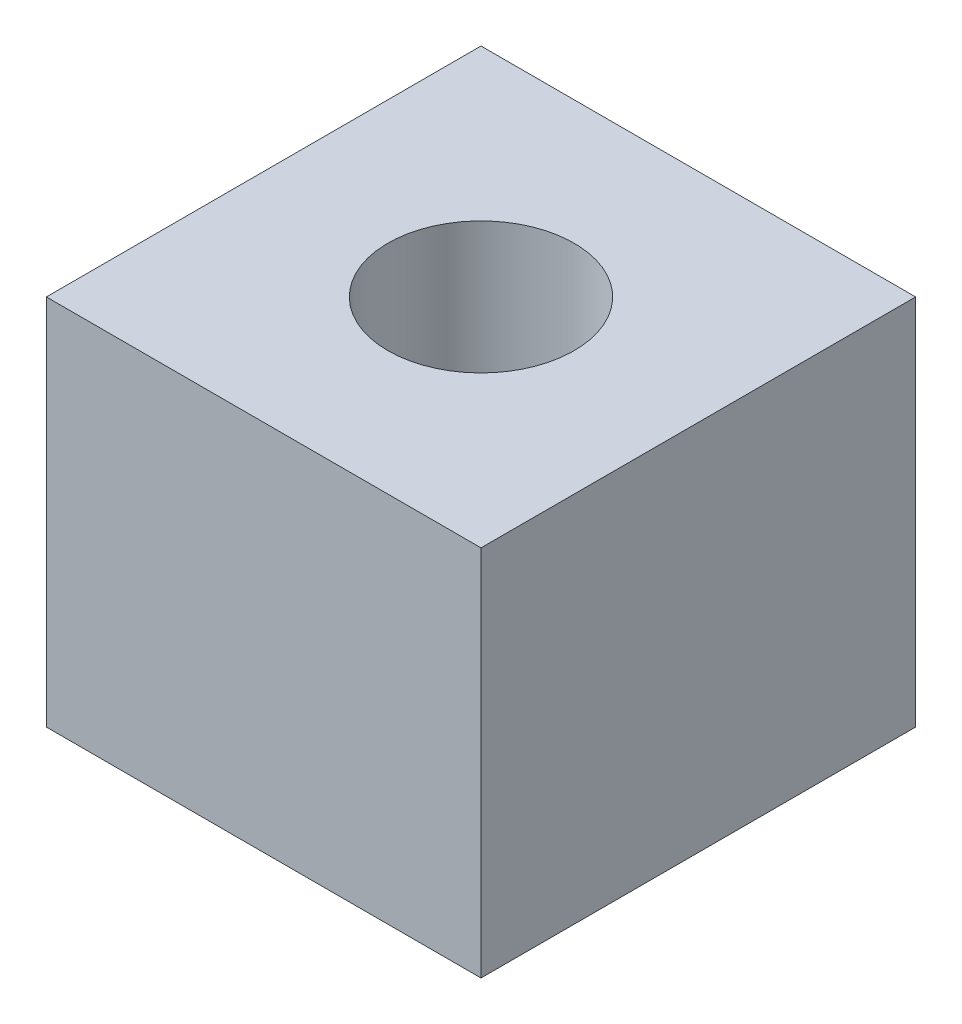
from build123d import *

# Parameters (mm, degrees)
SKETCH1_W           = 35
SKETCH1_H           = 35
BOSS_EXTRUDE1_DEPTH = 30
SKETCH2_R           = 7.5
CUT_EXTRUDE1_DEPTH  = 20


with BuildPart() as part:
    # Sketch1 → Boss-Extrude1 (new body)
    with BuildSketch(Plane(origin=(0, 0, 0), x_dir=(1, 0, 0), z_dir=(0, 1, 0))):
        Rectangle(SKETCH1_W, SKETCH1_H)
    extrude(amount=BOSS_EXTRUDE1_DEPTH)

    # Sketch2 → Cut-Extrude1 (cut)
    with BuildSketch(Plane(origin=(0, 30, 0), x_dir=(1, 0, 0), z_dir=(0, 1, 0))):
        Circle(SKETCH2_R)
    extrude(amount=-CUT_EXTRUDE1_DEPTH, mode=Mode.SUBTRACT)


solid = part.part
